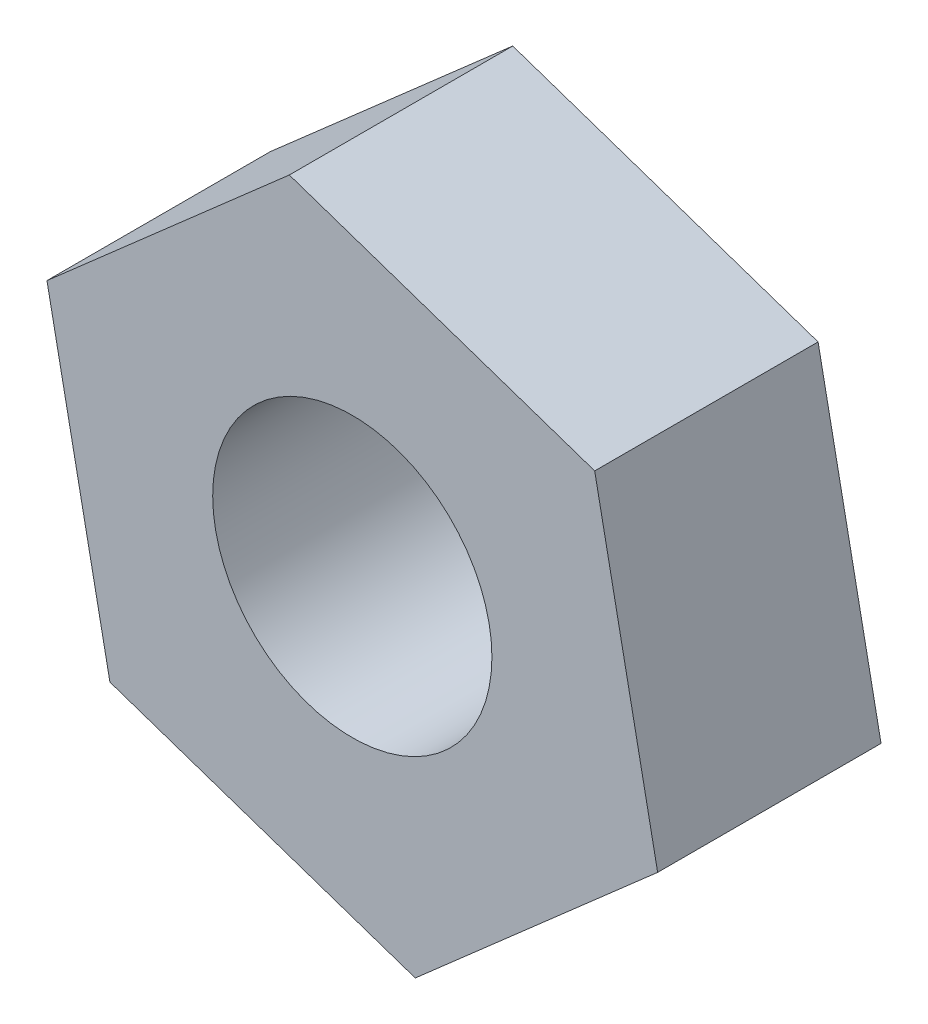
from build123d import *

# Parameters (mm, degrees)
SKETCH_1_R      = 1.25
EXTRUDE_1_DEPTH = 2


with BuildPart() as part:
    # 草图1 → 凸台-拉伸1 (new body)
    with BuildSketch(Plane.XY):
        Polygon((2.733728337, -0.927395663), (2.170012372, 1.903780355), (-0.563715965, 2.831176018), (-2.733728337, 0.927395663), (-2.170012372, -1.903780355), (0.563715965, -2.831176018), align=None)
        Circle(SKETCH_1_R, mode=Mode.SUBTRACT)
    extrude(amount=EXTRUDE_1_DEPTH)


solid = part.part
